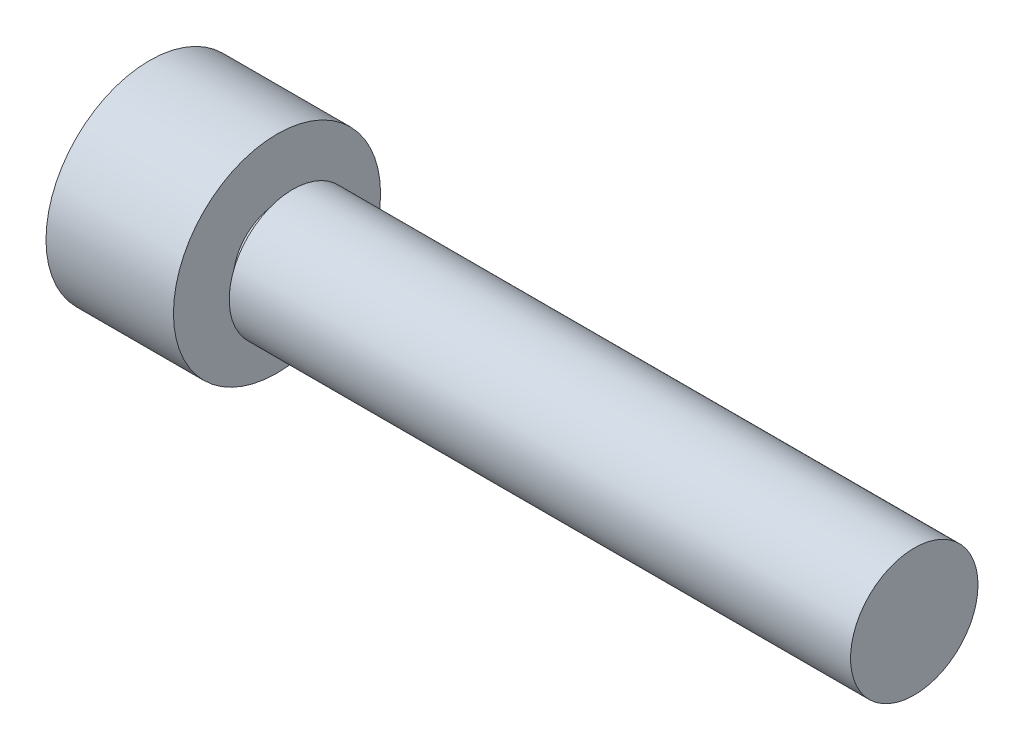
from build123d import *


with BuildPart() as part:
    # Sketch2 → Revolve1 (revolve)
    with BuildSketch(Plane(origin=(0, 0, 0), x_dir=(1, 0, 0), z_dir=(0, 1, 0))):
        Polygon((0, 0), (-46.6, 0), (-48, 0), (-48, 6.5), (-40, 6.5), (-40, 2.75), (-39, 2.75), (-39, 4), (0, 4), align=None)
    revolve(axis=Axis((0, 0, 0), (-1, 0, 0)))


solid = part.part
